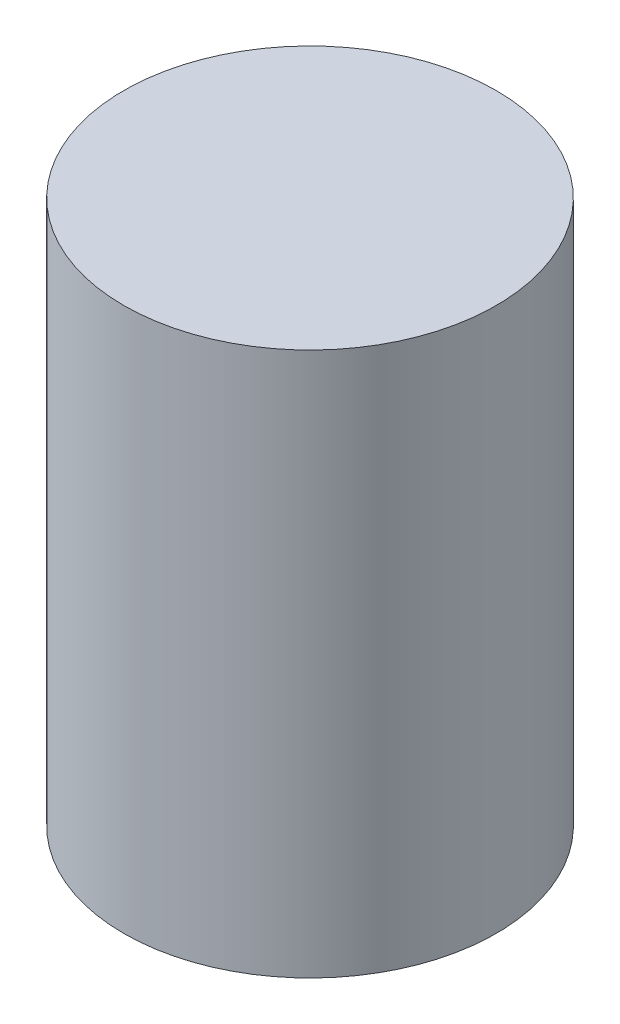
from build123d import *

# Parameters (mm, degrees)
SKETCH1_R           = 15.75
BOSS_EXTRUDE1_DEPTH = 46


with BuildPart() as part:
    # Sketch1 → Boss-Extrude1 (new body)
    with BuildSketch(Plane(origin=(0, 0, 0), x_dir=(1, 0, 0), z_dir=(0, 1, 0))):
        Circle(SKETCH1_R)
    extrude(amount=BOSS_EXTRUDE1_DEPTH)


solid = part.part
